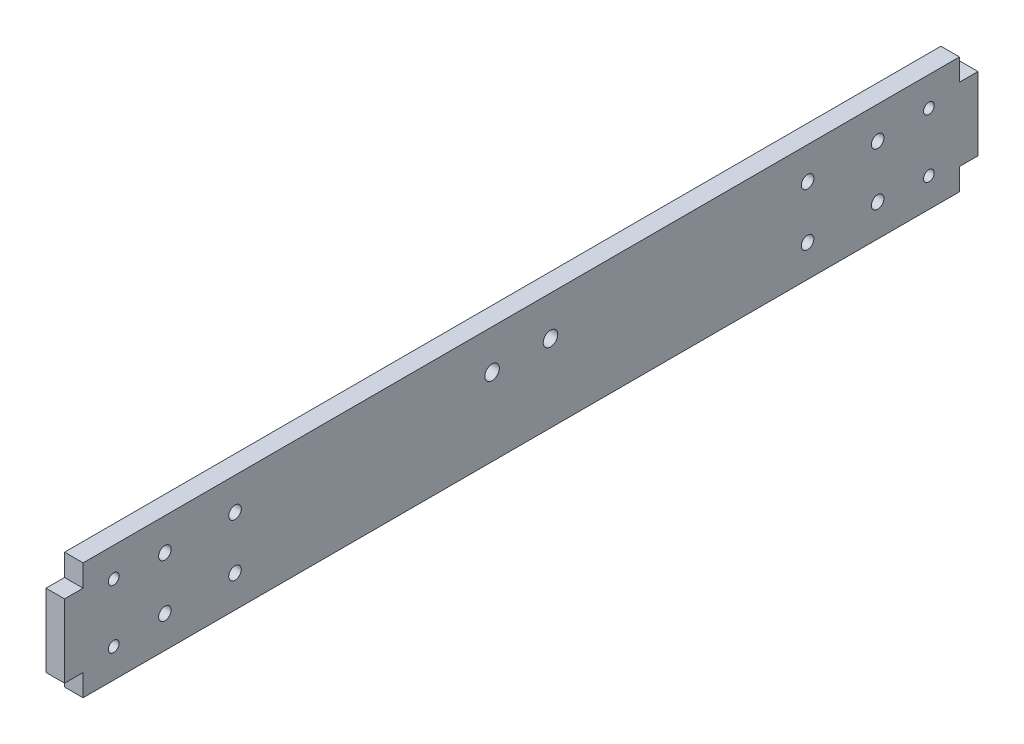
from build123d import *

# Parameters (mm, degrees)
SKETCH1_W              = 300
SKETCH1_H              = 40
BOSS_EXTRUDE1_DEPTH    = 6.35
SKETCH2_W              = 6.35
SKETCH2_H              = 25
BOSS_EXTRUDE2_DEPTH    = 6.35
F_10_CLEARANCE_HOLE1_D = 4.9784
F_8_CLEARANCE_HOLE1_D  = 4.3053
F_6_CLEARANCE_HOLE1_D  = 3.6576


with BuildPart() as part:
    # Sketch1 → Boss-Extrude1 (new body)
    with BuildSketch(Plane(origin=(0, 0, 0), x_dir=(0, 0, -1), z_dir=(1, 0, 0))):
        Rectangle(SKETCH1_W, SKETCH1_H)
    extrude(amount=BOSS_EXTRUDE1_DEPTH)

    # Sketch2 → Boss-Extrude2 (add)
    with BuildSketch(Plane(origin=(6.35, 0, 0), x_dir=(0, 0, -1), z_dir=(1, 0, 0))):
        with Locations((-153.175, 0)):
            Rectangle(SKETCH2_W, SKETCH2_H)
        with Locations((153.175, 0)):
            Rectangle(SKETCH2_W, SKETCH2_H)
    extrude(amount=-BOSS_EXTRUDE2_DEPTH)

    # #10 Clearance Hole1 (through all)
    with Locations(Plane(origin=(6.35, 0, 0), x_dir=(0, 0, -1), z_dir=(1, 0, 0))):
        with Locations((-10, 6.5), (10, 6.5)):
            Hole(F_10_CLEARANCE_HOLE1_D / 2)

    # #8 Clearance Hole1 (through all)
    with Locations(Plane(origin=(6.35, 0, 0), x_dir=(0, 0, -1), z_dir=(1, 0, 0))):
        with Locations((-122, 9), (-98, 9), (-98, -9), (-122, -9), (98, 9), (122, 9), (122, -9), (98, -9)):
            Hole(F_8_CLEARANCE_HOLE1_D / 2)

    # #6 Clearance Hole1 (through all)
    with Locations(Plane(origin=(6.35, 10, 139.5352), x_dir=(0, 0, 1), z_dir=(1, 0, 0))):
        with Locations((0, 0), (0, 20), (-279.0704, 0), (-279.0704, 20)):
            Hole(F_6_CLEARANCE_HOLE1_D / 2)


solid = part.part
